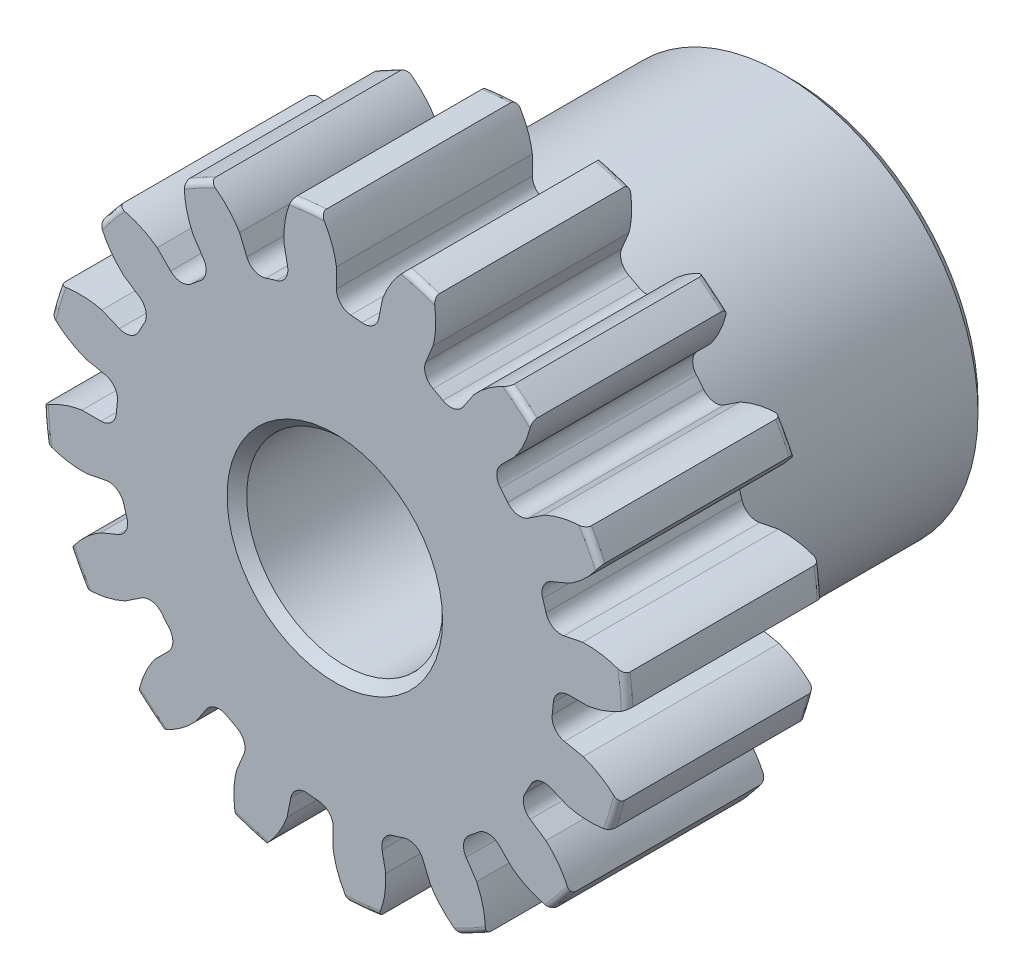
from build123d import *

# Parameters (mm, degrees)
SKETCH1_R                = 7.112
BOSS_EXTRUDE1_DEPTH      = 4.7625
SKETCH2_W                = 6.35
SKETCH2_H                = 4.7625
FILLET2_R                = 0.14224
CUT_EXTRUDE1_DEPTH       = 12.1125
FILLET1_R                = 0.37404675
CIRPATTERN1_COUNT        = 16
FILLET1_OF_CIRPATTERN1_R = 0.37404675
SKETCH5_R                = 2.38125
CUT_EXTRUDE2_DEPTH       = 12.1125
CHAMFER1_SIZE            = 0.238125


with BuildPart() as part:
    # Sketch1 → Boss-Extrude1 (new body)
    with BuildSketch(Plane.XY):
        Circle(SKETCH1_R)
    extrude(amount=-BOSS_EXTRUDE1_DEPTH)

    # Sketch2 → Revolve1 (revolve)
    with BuildSketch(Plane(origin=(0, 0, 0), x_dir=(0, 0, -1), z_dir=(1, 0, 0))):
        with Locations((7.9375, 2.38125)):
            Rectangle(SKETCH2_W, SKETCH2_H)
    revolve(axis=Axis((0, 0, -4.7625), (0, 0, -1)))

    # Fillet2
    fillet2_edges = [part.edges().sort_by_distance(p)[0] for p in [
        (-7.112, 0, 0),
        (-7.112, 0, -4.7625),
        (0, -4.7625, -4.7625),
    ]]
    fillet(fillet2_edges, radius=FILLET2_R)

    # Sketch4 → Cut-Extrude1 (cut, through all)
    with BuildSketch(Plane.XY):
        with BuildLine():
            Line((0.039756598, 6.147608965), (0.039756598, 5.325914116))
            ThreePointArc((0.039756598, 5.325914116), (0.522046632, 5.300415933), (1.000044016, 5.231333838))
            Line((1.000044016, 5.231333838), (1.160349098, 6.037239977))
            add(Edge.make_bspline(
                [(2.084637688, 7.187445149), (1.4115305, 6.736849805), (1.160349098, 6.037239977)],
                knots=[0, 0, 0, 1, 1, 1], degree=2))
            ThreePointArc((2.084637688, 7.187445149), (0.733528106, 7.447618316), (-0.642377547, 7.456033339))
            add(Edge.make_bspline(
                [(-0.642377547, 7.456033339), (-0.070110979, 6.882779097), (0.039756598, 6.147608965)],
                knots=[0, 0, 0, 1, 1, 1], degree=2))
        make_face()
    cut_extrude1 = extrude(amount=-CUT_EXTRUDE1_DEPTH, mode=Mode.SUBTRACT)

    # Fillet1
    fillet1_edges = [part.edges().sort_by_distance(p)[0] for p in [
        (1.000044016, 5.231333838, -2.38125),
        (0.039756598, 5.325914116, -2.38125),
    ]]
    fillet(fillet1_edges, radius=FILLET1_R)

    # CirPattern1: Cut-Extrude1 ×16 about axis
    cirpattern1_axis = Axis((0, 0, -4.7625), (0, 0, 1))
    for i in range(1, CIRPATTERN1_COUNT):
        add(cut_extrude1.rotate(cirpattern1_axis, i * 360 / CIRPATTERN1_COUNT), mode=Mode.SUBTRACT)

    # Fillet1 of CirPattern1
    fillet1_of_cirpattern1_edges = [part.edges().sort_by_distance(p)[0] for p in [
        (-1.078024591, 5.215822537, -2.38125),
        (-2.001408787, 4.935717235, -2.38125),
        (-2.991973726, 4.406249536, -2.38125),
        (-3.737877827, 3.794102147, -2.38125),
        (-4.450421984, 2.925864986, -2.38125),
        (-4.905288852, 2.074869402, -2.38125),
        (-5.231333838, 1.000044016, -2.38125),
        (-5.325914116, 0.039756598, -2.38125),
        (-5.215822537, -1.078024591, -2.38125),
        (-4.935717235, -2.001408787, -2.38125),
        (-4.406249536, -2.991973726, -2.38125),
        (-3.794102147, -3.737877827, -2.38125),
        (-2.925864986, -4.450421984, -2.38125),
        (-2.074869402, -4.905288852, -2.38125),
        (-1.000044016, -5.231333838, -2.38125),
        (-0.039756598, -5.325914116, -2.38125),
        (1.078024591, -5.215822537, -2.38125),
        (2.001408787, -4.935717235, -2.38125),
        (2.991973726, -4.406249536, -2.38125),
        (3.737877827, -3.794102147, -2.38125),
        (4.450421984, -2.925864986, -2.38125),
        (4.905288852, -2.074869402, -2.38125),
        (5.231333838, -1.000044016, -2.38125),
        (5.325914116, -0.039756598, -2.38125),
        (5.215822537, 1.078024591, -2.38125),
        (4.935717235, 2.001408787, -2.38125),
        (4.406249536, 2.991973726, -2.38125),
        (3.794102147, 3.737877827, -2.38125),
        (2.925864986, 4.450421984, -2.38125),
        (2.074869402, 4.905288852, -2.38125),
    ]]
    fillet(fillet1_of_cirpattern1_edges, radius=FILLET1_OF_CIRPATTERN1_R)

    # Sketch5 → Cut-Extrude2 (cut, through all)
    with BuildSketch(Plane.XY):
        Circle(SKETCH5_R)
    extrude(amount=-CUT_EXTRUDE2_DEPTH, mode=Mode.SUBTRACT)

    # Chamfer1
    chamfer1_edges = [part.edges().sort_by_distance(p)[0] for p in [
        (0, -4.7625, -11.1125),
        (-2.38125, 0, -11.1125),
        (-2.38125, 0, 0),
    ]]
    chamfer(chamfer1_edges, length=CHAMFER1_SIZE)


solid = part.part
